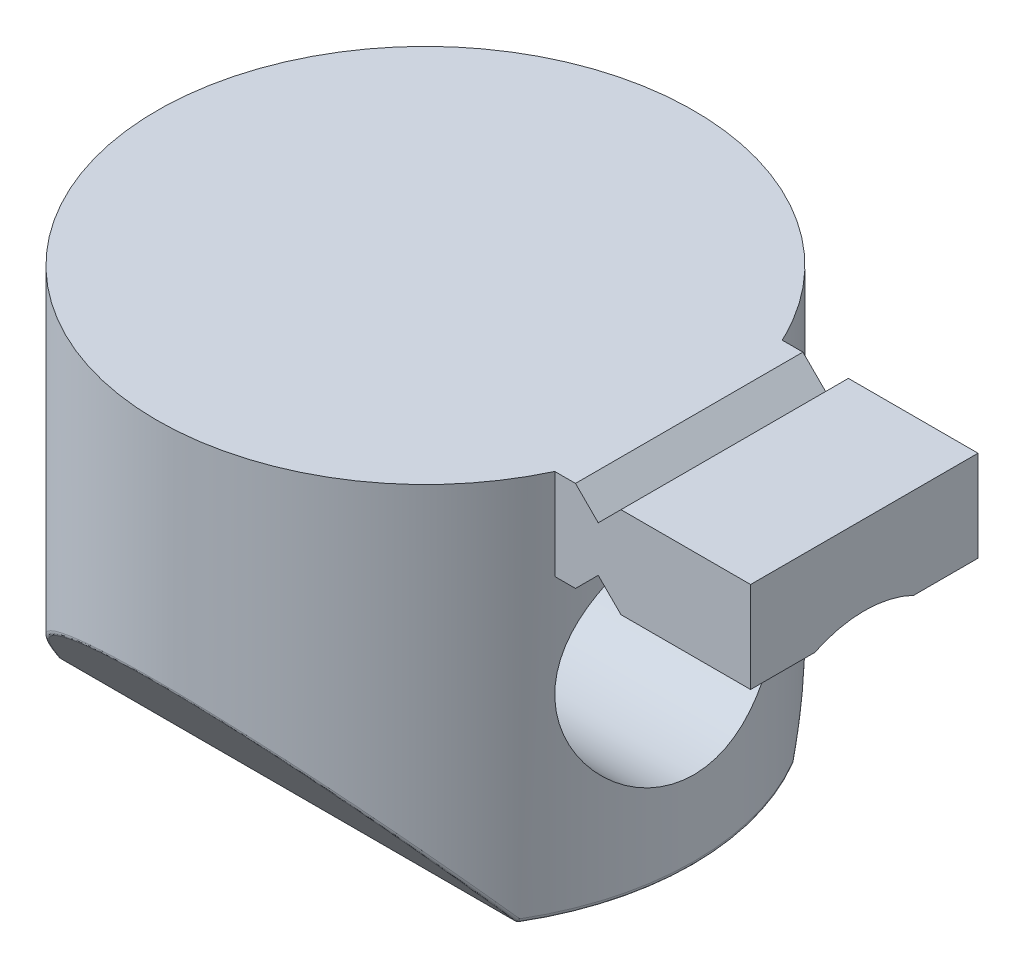
from build123d import *

# Parameters (mm, degrees)
SKETCH1_R          = 5.9
EXTRUDE1_DEPTH     = 8.5
SKETCH2_W          = 9.65
SKETCH2_H          = 5
EXTRUDE2_DEPTH     = 2
SKETCH3_R          = 2.5
CUT_EXTRUDE1_DEPTH = 16.55
CUT_EXTRUDE2_DEPTH = 9.4000001
CUT_EXTRUDE3_DEPTH = 16.5500001
FILLET2_R          = 0.1
CUT_EXTRUDE5_DEPTH = 7


with BuildPart() as part:
    # Sketch1 → Extrude1 (new body)
    with BuildSketch(Plane(origin=(0, 0, 0), x_dir=(1, 0, 0), z_dir=(0, 1, 0))):
        Circle(SKETCH1_R)
    extrude(amount=EXTRUDE1_DEPTH)

    # Sketch2 → Extrude2 (add)
    with BuildSketch(Plane(origin=(0, 8.5, 0), x_dir=(1, 0, 0), z_dir=(0, 1, 0))):
        with Locations((4.825, 0)):
            Rectangle(SKETCH2_W, SKETCH2_H)
    extrude(amount=-EXTRUDE2_DEPTH)

    # Sketch3 → Cut-Extrude1 (cut, through all)
    with BuildSketch(Plane(origin=(9.65, 0, 0), x_dir=(0, 0, -1), z_dir=(1, 0, 0))):
        with Locations((0, 4.25)):
            Circle(SKETCH3_R)
    extrude(amount=-CUT_EXTRUDE1_DEPTH, mode=Mode.SUBTRACT)

    # Sketch4 → Cut-Extrude2 (cut, through all)
    with BuildSketch(Plane.XY.offset(2.5)):
        Polygon((6.8, 8.5), (5.8, 8.5), (6.3, 8), align=None)
        Polygon((6.3, 7), (5.8, 6.5), (6.8, 6.5), align=None)
    extrude(amount=-CUT_EXTRUDE2_DEPTH, mode=Mode.SUBTRACT)

    # Sketch5 → Cut-Extrude3 (cut, through all)
    with BuildSketch(Plane(origin=(9.65, 0, 0), x_dir=(0, 0, -1), z_dir=(1, 0, 0))):
        Polygon((-5.9, 3.5), (-6.106265144, 3.5), (-6.003132572, -0.278643129), (6.106265144, -0.15610938), (6.106265144, 3.632225684), (5.9, 3.5), (3, 0), (-3, 0), align=None)
    extrude(amount=-CUT_EXTRUDE3_DEPTH, mode=Mode.SUBTRACT)

    # Fillet2
    fillet2_edges = [part.edges().sort_by_distance(p)[0] for p in [
        (5.691400991, 0, -1.554977415),
        (-5.9, 0, 0),
        (0, 0, -3),
        (0, 0, 3),
        (-3.201105027, 2.360810271, 4.956099939),
        (3.201105027, 2.360810271, -4.956099939),
    ]]
    fillet(fillet2_edges, radius=FILLET2_R)

    # Sketch7 → Cut-Extrude5 (cut)
    with BuildSketch(Plane(origin=(-5.9, 0, 0), x_dir=(0, 0, -1), z_dir=(1, 0, 0))):
        Polygon((-4, 4.25), (-2, 7.714101615), (2, 7.714101615), (4, 4.25), (2, 0.785898385), (-2, 0.785898385), align=None)
    extrude(amount=CUT_EXTRUDE5_DEPTH, mode=Mode.SUBTRACT)


solid = part.part
